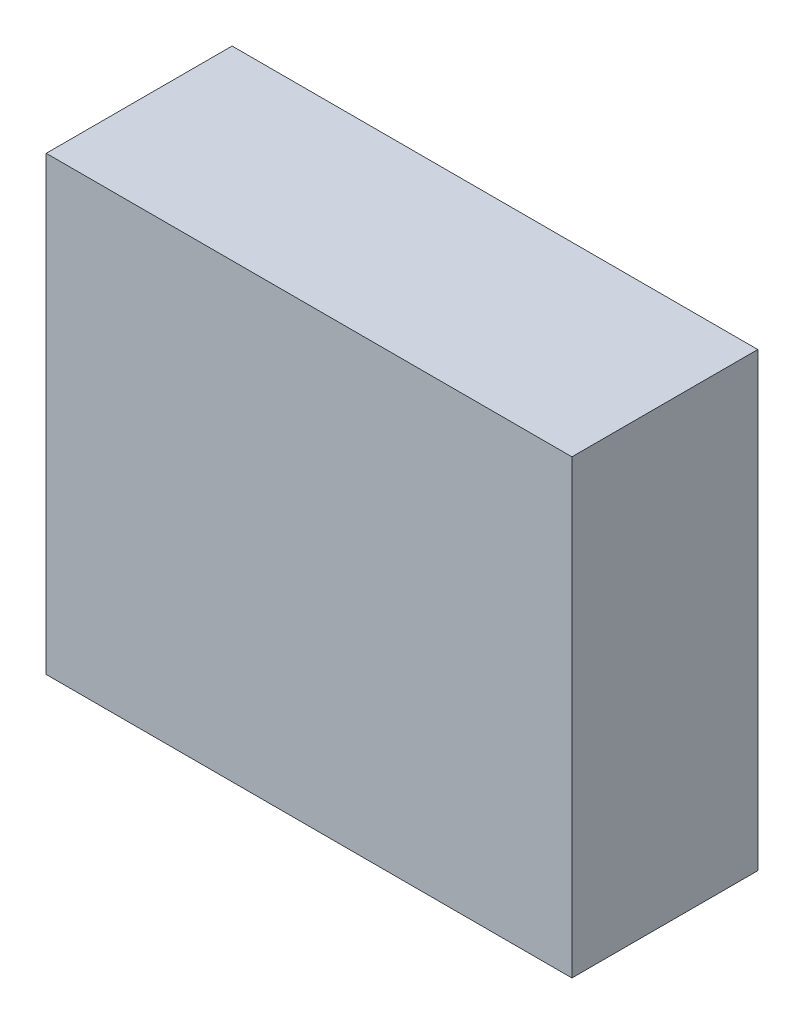
from build123d import *

# Parameters (mm, degrees)
SKETCH1_W           = 99
SKETCH1_H           = 35
BOSS_EXTRUDE1_DEPTH = 85


with BuildPart() as part:
    # Sketch1 → Boss-Extrude1 (new body)
    with BuildSketch(Plane(origin=(0, 0, 0), x_dir=(1, 0, 0), z_dir=(0, 1, 0))):
        Rectangle(SKETCH1_W, SKETCH1_H)
    extrude(amount=BOSS_EXTRUDE1_DEPTH)


solid = part.part
